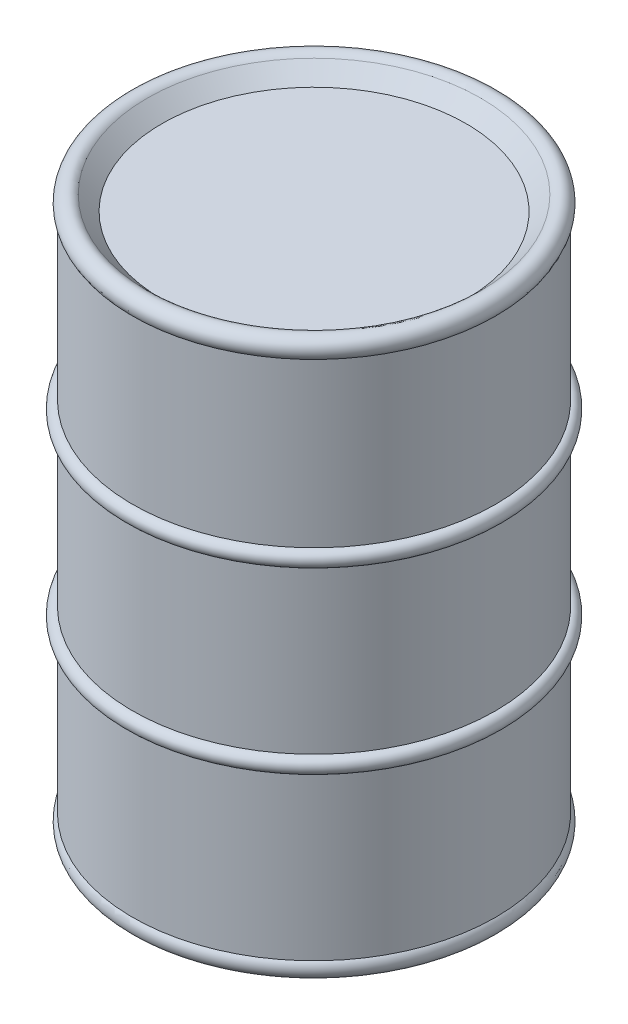
from build123d import *


with BuildPart() as part:
    # Sketch1 → Revolve1 (revolve)
    with BuildSketch(Plane.XY):
        with BuildLine():
            Line((292.1, 0), (292.1, 262.466666667))
            ThreePointArc((292.1, 262.466666667), (304.8, 275.166666667), (292.1, 287.866666667))
            Line((292.1, 287.866666667), (292.1, 550.333333333))
            ThreePointArc((292.1, 550.333333333), (304.8, 563.033333333), (292.1, 575.733333333))
            Line((292.1, 575.733333333), (292.1, 838.2))
            ThreePointArc((292.1, 838.2), (292.1, 861.87230509), (268.42769491, 861.87230509))
            Line((268.42769491, 861.87230509), (244.755389821, 838.2))
            Line((244.755389821, 838.2), (0, 838.2))
            Line((0, 838.2), (0, 837.28814))
            Line((0, 837.28814), (291.18814, 837.28814))
            Line((291.18814, 837.28814), (291.18814, 0.91186))
            Line((291.18814, 0.91186), (0, 0.91186))
            Line((0, 0.91186), (0, 0))
            Line((0, 0), (244.755389821, 0))
            Line((244.755389821, 0), (268.42769491, -23.67230509))
            ThreePointArc((268.42769491, -23.67230509), (292.1, -23.67230509), (292.1, 0))
        make_face()
    revolve(axis=Axis((0, 0.91186, 0), (0, 1, 0)))


solid = part.part
